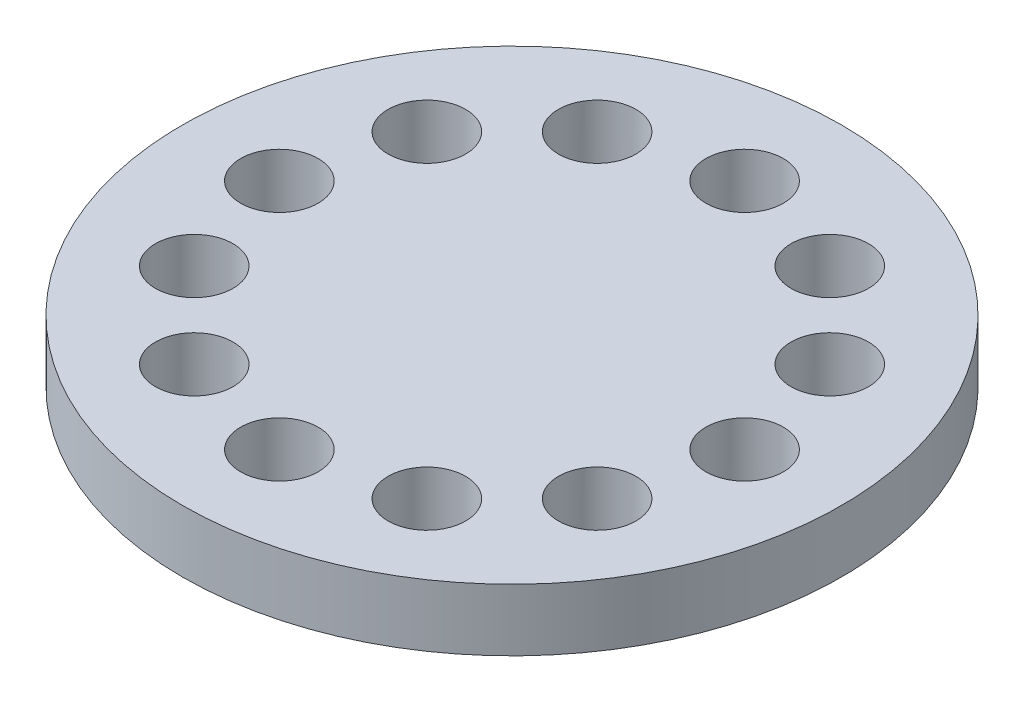
from build123d import *

# Parameters (mm, degrees)
SKETCH1_R           = 13.49375
BOSS_EXTRUDE1_DEPTH = 2.54
SKETCH2_R           = 1.5875
CUT_EXTRUDE1_DEPTH  = 20.251342242
CIRPATTERN1_COUNT   = 12


with BuildPart() as part:
    # Sketch1 → Boss-Extrude1 (new body)
    with BuildSketch(Plane(origin=(0, 0, 0), x_dir=(1, 0, 0), z_dir=(0, 1, 0))):
        Circle(SKETCH1_R)
    extrude(amount=BOSS_EXTRUDE1_DEPTH)

    # Sketch2 → Cut-Extrude1 (cut, symmetric)
    with BuildSketch(Plane(origin=(0, 2.54, 0), x_dir=(1, 0, 0), z_dir=(0, 1, 0))):
        with Locations((-9.525, 0)):
            Circle(SKETCH2_R)
    cut_extrude1 = extrude(amount=CUT_EXTRUDE1_DEPTH, both=True, mode=Mode.SUBTRACT)

    # CirPattern1: Cut-Extrude1 ×12 about axis
    cirpattern1_axis = Axis((0, 2.54, 0), (0, -1, 0))
    for i in range(1, CIRPATTERN1_COUNT):
        add(cut_extrude1.rotate(cirpattern1_axis, i * 360 / CIRPATTERN1_COUNT), mode=Mode.SUBTRACT)


solid = part.part
